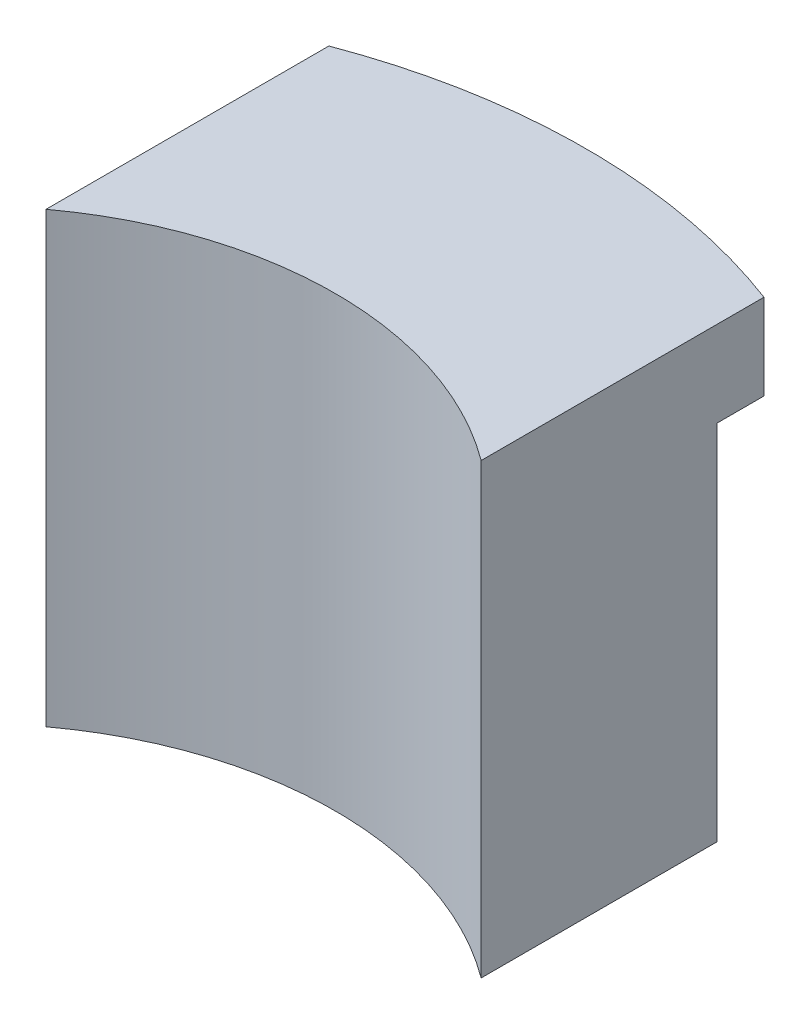
from build123d import *

# Parameters (mm, degrees)
BOSS_EXTRUDE2_DEPTH  = 2
BOSS_EXTRUDE9_DEPTH  = 3
BOSS_EXTRUDE10_DEPTH = 0.9
SKETCH20_R           = 3.25
CUT_EXTRUDE14_DEPTH  = 20.9
SKETCH21_W           = 30
SKETCH21_H           = 16.85185618
CUT_EXTRUDE15_DEPTH  = 1
BOSS_EXTRUDE11_DEPTH = 25
SKETCH23_W           = 0.5
SKETCH23_H           = 24.1
BOSS_EXTRUDE12_DEPTH = 0.9
BOSS_EXTRUDE13_DEPTH = 0.9


with BuildPart() as part:
    # Sketch1 → Boss-Extrude2 (new body)
    with BuildSketch(Plane(origin=(0, 0, 0), x_dir=(1, 0, 0), z_dir=(0, 1, 0))):
        with BuildLine():
            Line((-15, 39.764934301), (-15, 20.264934301))
            ThreePointArc((-15, 20.264934301), (0, 25.212448557), (15, 20.264934301))
            Line((15, 20.264934301), (15, 39.764934301))
            ThreePointArc((15, 39.764934301), (0, 42.5), (-15, 39.764934301))
        make_face()
    extrude(amount=BOSS_EXTRUDE2_DEPTH)

    # Sketch16 → Boss-Extrude9 (add)
    with BuildSketch(Plane.XZ):
        with BuildLine():
            Line((-15, -20.264934301), (-15, -39.764934301))
            ThreePointArc((-15, -39.764934301), (0, -42.5), (15, -39.764934301))
            Line((15, -39.764934301), (15, -20.264934301))
            ThreePointArc((15, -20.264934301), (0, -25.212448557), (-15, -20.264934301))
        make_face()
        with BuildLine():
            ThreePointArc((-13, -38.356876828), (0, -40.5), (13, -38.356876828))
            Line((13, -38.356876828), (13, -23.906429187))
            ThreePointArc((13, -23.906429187), (0, -27.212448557), (-13, -23.906429187))
            Line((-13, -23.906429187), (-13, -38.356876828))
        make_face(mode=Mode.SUBTRACT)
    extrude(amount=BOSS_EXTRUDE9_DEPTH)

    # Sketch17 → Boss-Extrude10 (add)
    with BuildSketch(Plane.XZ.offset(3)):
        with BuildLine():
            ThreePointArc((15, -20.264934301), (0, -25.212448557), (-15, -20.264934301))
            Line((-15, -20.264934301), (-15, -39.764934301))
            ThreePointArc((-15, -39.764934301), (0, -42.5), (15, -39.764934301))
            Line((15, -39.764934301), (15, -20.264934301))
        make_face()
        with BuildLine():
            ThreePointArc((-14.5, -39.417635647), (0, -42), (14.5, -39.417635647))
            Line((14.5, -39.417635647), (14.5, -21.233935358))
            ThreePointArc((14.5, -21.233935358), (0, -25.712448557), (-14.5, -21.233935358))
            Line((-14.5, -21.233935358), (-14.5, -39.417635647))
        make_face(mode=Mode.SUBTRACT)
    extrude(amount=BOSS_EXTRUDE10_DEPTH)

    # Sketch20 → Cut-Extrude14 (cut)
    with BuildSketch(Plane.XY.offset(-50)):
        with Locations((0, -3.9)):
            Circle(SKETCH20_R)
    extrude(amount=CUT_EXTRUDE14_DEPTH, mode=Mode.SUBTRACT)

    # Sketch21 → Cut-Extrude15 (cut)
    with BuildSketch(Plane.XZ.offset(3)):
        with Locations((0, -27.189006211)):
            Rectangle(SKETCH21_W, SKETCH21_H)
    extrude(amount=CUT_EXTRUDE15_DEPTH, mode=Mode.SUBTRACT)

    # Sketch22 → Boss-Extrude11 (add)
    with BuildSketch(Plane.XZ.offset(3)):
        with BuildLine():
            Line((15, -20.264934301), (15, -35.614934301))
            Line((15, -35.614934301), (13, -35.614934301))
            Line((13, -35.614934301), (13, -23.906429187))
            ThreePointArc((13, -23.906429187), (0, -27.212448557), (-13, -23.906429187))
            Line((-13, -23.906429187), (-13, -35.614934301))
            Line((-13, -35.614934301), (-15, -35.614934301))
            Line((-15, -35.614934301), (-15, -20.264934301))
            ThreePointArc((-15, -20.264934301), (0, -25.212448557), (15, -20.264934301))
        make_face()
    extrude(amount=BOSS_EXTRUDE11_DEPTH)

    # Sketch23 → Boss-Extrude12 (add)
    with BuildSketch(Plane(origin=(0, 0, -35.614934301), x_dir=(-1, 0, 0), z_dir=(0, 0, -1))):
        with Locations((-14.75, -15.95)):
            Rectangle(SKETCH23_W, SKETCH23_H)
        with Locations((14.75, -15.95)):
            Rectangle(SKETCH23_W, SKETCH23_H)
    extrude(amount=BOSS_EXTRUDE12_DEPTH)

    # Sketch26 → Boss-Extrude13 (add)
    with BuildSketch(Plane.XZ.offset(28)):
        with BuildLine():
            Line((15, -36.514934301), (15, -20.264934301))
            ThreePointArc((15, -20.264934301), (0, -25.212448557), (-15, -20.264934301))
            Line((-15, -20.264934301), (-15, -36.514934301))
            Line((-15, -36.514934301), (-14.5, -36.514934301))
            Line((-14.5, -36.514934301), (-14.5, -21.233935358))
            ThreePointArc((-14.5, -21.233935358), (0, -25.712448557), (14.5, -21.233935358))
            Line((14.5, -21.233935358), (14.5, -36.514934301))
            Line((14.5, -36.514934301), (15, -36.514934301))
        make_face()
    extrude(amount=BOSS_EXTRUDE13_DEPTH)


solid = part.part
